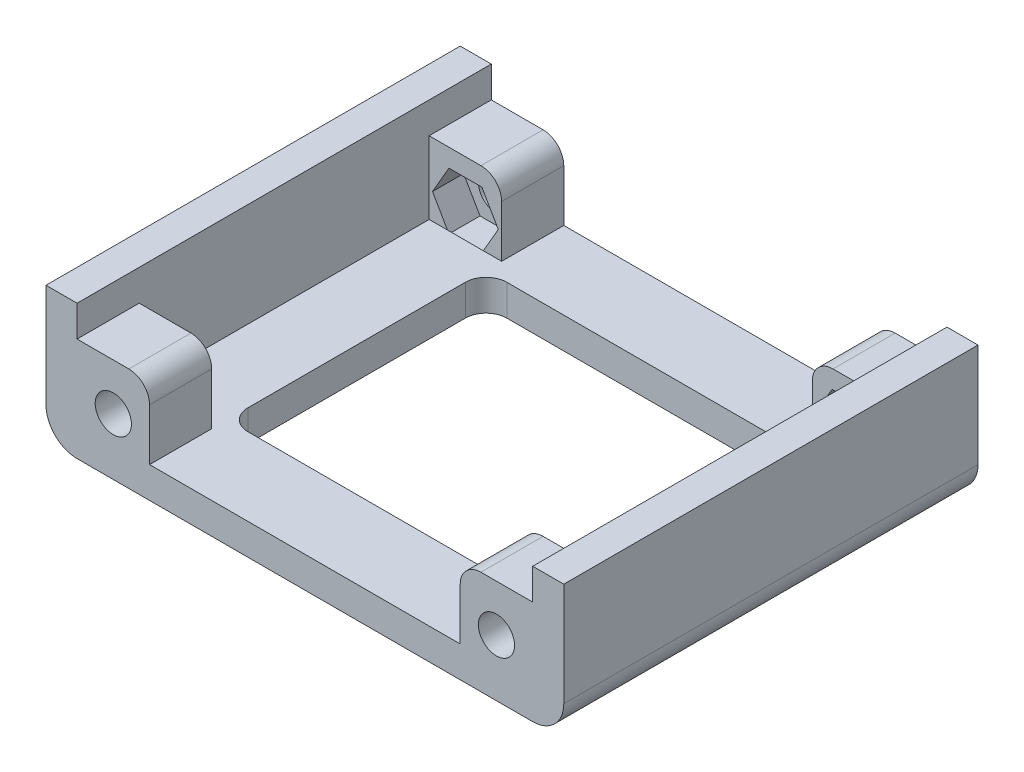
from build123d import *

# Parameters (mm, degrees)
SKETCH1_W            = 50
SKETCH1_H            = 40
BOSS_EXTRUDE1_DEPTH  = 3
SKETCH2_W            = 30
SKETCH2_H            = 25
CUT_EXTRUDE1_DEPTH   = 4
SKETCH3_W            = 3
SKETCH3_H            = 40
BOSS_EXTRUDE2_DEPTH  = 10
SKETCH4_W            = 7
SKETCH4_H            = 7
BOSS_EXTRUDE3_DEPTH  = 6
SKETCH5_R            = 1.75
CUT_EXTRUDE2_DEPTH   = 41
CUT_EXTRUDE3_DEPTH   = 3
MIRROR3_COPY_1_DEPTH = 3
FILLET1_R            = 3
FILLET2_R            = 2
FILLET3_R            = 2


with BuildPart() as part:
    # Sketch1 → Boss-Extrude1 (new body)
    with BuildSketch(Plane(origin=(0, 0, 0), x_dir=(1, 0, 0), z_dir=(0, 1, 0))):
        Rectangle(SKETCH1_W, SKETCH1_H)
    extrude(amount=BOSS_EXTRUDE1_DEPTH)

    # Sketch2 → Cut-Extrude1 (cut, through all)
    with BuildSketch(Plane(origin=(0, 3, 0), x_dir=(1, 0, 0), z_dir=(0, 1, 0))):
        Rectangle(SKETCH2_W, SKETCH2_H)
    extrude(amount=-CUT_EXTRUDE1_DEPTH, mode=Mode.SUBTRACT)

    # Sketch3 → Boss-Extrude2 (add)
    with BuildSketch(Plane(origin=(0, 3, 0), x_dir=(1, 0, 0), z_dir=(0, 1, 0))):
        with Locations((-23.5, 0)):
            Rectangle(SKETCH3_W, SKETCH3_H)
        with Locations((23.5, 0)):
            Rectangle(SKETCH3_W, SKETCH3_H)
    extrude(amount=BOSS_EXTRUDE2_DEPTH)

    # Sketch4 → Boss-Extrude3 (add)
    with BuildSketch(Plane.XY.offset(20)):
        with Locations((-18.5, 6.5)):
            Rectangle(SKETCH4_W, SKETCH4_H)
        with Locations((18.5, 6.5)):
            Rectangle(SKETCH4_W, SKETCH4_H)
    boss_extrude3 = extrude(amount=-BOSS_EXTRUDE3_DEPTH)

    # Sketch5 → Cut-Extrude2 (cut, through all)
    with BuildSketch(Plane.XY.offset(20)):
        with Locations((-18.5, 5.5)):
            Circle(SKETCH5_R)
        with Locations((18.5, 5.5)):
            Circle(SKETCH5_R)
    cut_extrude2 = extrude(amount=-CUT_EXTRUDE2_DEPTH, mode=Mode.SUBTRACT)

    # Mirror1: Boss-Extrude3, Cut-Extrude2 across plane
    add(boss_extrude3.mirror(Plane.XY))
    add(cut_extrude2.mirror(Plane.XY), mode=Mode.SUBTRACT)

    # Sketch6 → Cut-Extrude3 (cut)
    with BuildSketch(Plane.XY.offset(-14)):
        Polygon((-15.324573519, 5.5), (-16.91228676, 8.25), (-20.08771324, 8.25), (-21.675426481, 5.5), (-20.08771324, 2.75), (-16.91228676, 2.75), align=None)
    cut_extrude3 = extrude(amount=-CUT_EXTRUDE3_DEPTH, mode=Mode.SUBTRACT)

    # Mirror2: Cut-Extrude3 across plane
    add(cut_extrude3.mirror(Plane(origin=(0, 0, 0), x_dir=(0, 0, 1), z_dir=(1, 0, 0))), mode=Mode.SUBTRACT)

    # Mirror3: Cut-Extrude3 across plane
    add(cut_extrude3.mirror(Plane.XY), mode=Mode.SUBTRACT)

    # Mirror3 copy 1 sketch → Mirror3 copy 1 (cut)
    with BuildSketch(Plane(origin=(0, 0, 14), x_dir=(-1, 0, 0), z_dir=(0, 0, -1))):
        Polygon((-15.324573519, 5.5), (-16.91228676, 8.25), (-20.08771324, 8.25), (-21.675426481, 5.5), (-20.08771324, 2.75), (-16.91228676, 2.75), align=None)
    extrude(amount=-MIRROR3_COPY_1_DEPTH, mode=Mode.SUBTRACT)

    # Fillet1
    fillet1_edges = [part.edges().sort_by_distance(p)[0] for p in [
        (-25, 0, 0),
        (25, 0, 0),
    ]]
    fillet(fillet1_edges, radius=FILLET1_R)

    # Fillet2
    fillet2_edges = [part.edges().sort_by_distance(p)[0] for p in [
        (15, 10, -17),
        (-15, 10, 17),
        (15, 10, 17),
        (-15, 10, -17),
    ]]
    fillet(fillet2_edges, radius=FILLET2_R)

    # Fillet3
    fillet3_edges = [part.edges().sort_by_distance(p)[0] for p in [
        (-15, 1.5, 12.5),
        (-15, 1.5, -12.5),
        (15, 1.5, -12.5),
        (15, 1.5, 12.5),
    ]]
    fillet(fillet3_edges, radius=FILLET3_R)


solid = part.part
